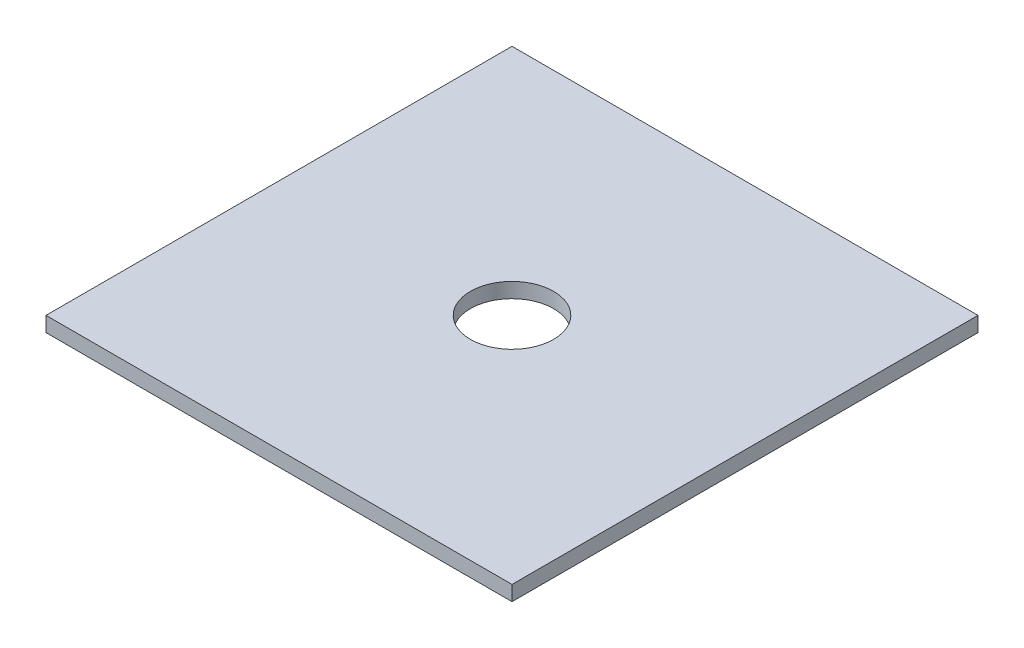
from build123d import *

# Parameters (mm, degrees)
SKETCH_1_W          = 560
SKETCH_1_H          = 560
EXTRUDE_1_DEPTH     = 18
SKETCH_2_R          = 50
CUT_EXTRUDE_1_DEPTH = 19


with BuildPart() as part:
    # 스케치1 → 보스-돌출1 (new body)
    with BuildSketch(Plane(origin=(0, 0, 0), x_dir=(1, 0, 0), z_dir=(0, 1, 0))):
        Rectangle(SKETCH_1_W, SKETCH_1_H)
    extrude(amount=EXTRUDE_1_DEPTH)

    # 스케치2 → 컷-돌출1 (cut, through all)
    with BuildSketch(Plane(origin=(0, 18, 0), x_dir=(1, 0, 0), z_dir=(0, 1, 0))):
        Circle(SKETCH_2_R)
    extrude(amount=-CUT_EXTRUDE_1_DEPTH, mode=Mode.SUBTRACT)


solid = part.part
